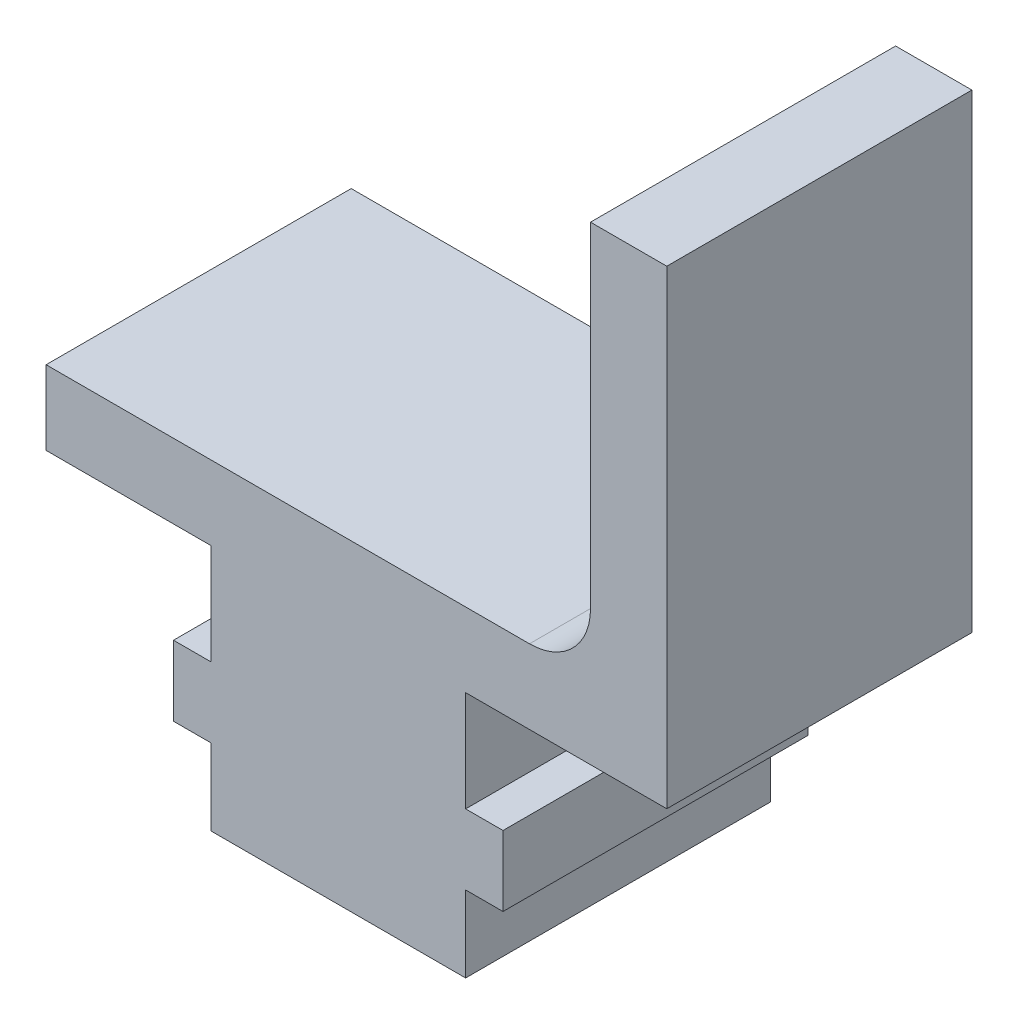
from build123d import *

# Parameters (mm, degrees)
BOSS_EXTRUDE1_DEPTH = 12.7
FILLET1_R           = 2.54


with BuildPart() as part:
    # Sketch1 → Boss-Extrude1 (new body)
    with BuildSketch(Plane.XY):
        Polygon((0, 0), (0, -4.191), (-1.55575, -4.191), (-1.55575, -7.112), (0, -7.112), (0, -10.287), (10.6045, -10.287), (10.6045, -7.112), (12.16025, -7.112), (12.16025, -4.191), (10.6045, -4.191), (10.6045, 0), (18.97725, 0), (18.97725, 19.558), (15.80225, 19.558), (15.80225, 3.089), (-6.858, 3.089), (-6.858, 0), align=None)
    extrude(amount=BOSS_EXTRUDE1_DEPTH)

    # Fillet1
    fillet1_edges = [part.edges().sort_by_distance(p)[0] for p in [
        (15.80225, 3.089, 6.35),
    ]]
    fillet(fillet1_edges, radius=FILLET1_R)


solid = part.part
